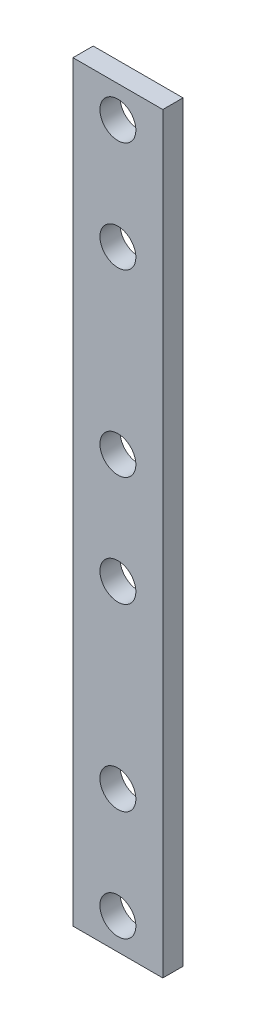
from build123d import *

# Parameters (mm, degrees)
SKETCH1_W           = 20
SKETCH1_H           = 167.5
BOSS_EXTRUDE1_DEPTH = 4.5
SKETCH2_R           = 4
CUT_EXTRUDE1_DEPTH  = 4.5


with BuildPart() as part:
    # Sketch1 → Boss-Extrude1 (new body)
    with BuildSketch(Plane.XY):
        with Locations((26.342010442, 1.25)):
            Rectangle(SKETCH1_W, SKETCH1_H)
    extrude(amount=BOSS_EXTRUDE1_DEPTH)

    # Sketch2 → Cut-Extrude1 (cut)
    with BuildSketch(Plane.XY.offset(4.5)):
        with Locations((26.342010442, -75.5)):
            Circle(SKETCH2_R)
        with Locations((26.342010442, -51)):
            Circle(SKETCH2_R)
        with Locations((26.342010442, -11)):
            Circle(SKETCH2_R)
        with Locations((26.342010442, 13.5)):
            Circle(SKETCH2_R)
        with Locations((26.342010442, 53.5)):
            Circle(SKETCH2_R)
        with Locations((26.342010442, 78)):
            Circle(SKETCH2_R)
    extrude(amount=-CUT_EXTRUDE1_DEPTH, mode=Mode.SUBTRACT)


solid = part.part
